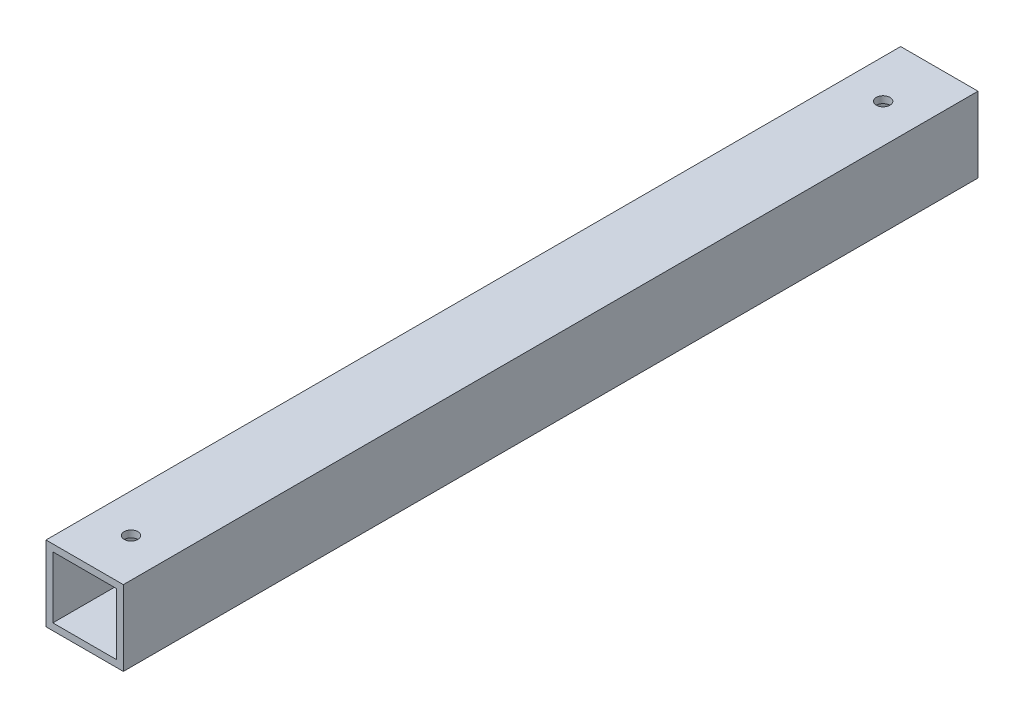
from build123d import *

# Parameters (mm, degrees)
SKETCH1_W           = 45.25
SKETCH1_H           = 44
SKETCH1_W_2         = 37.25
SKETCH1_H_2         = 36
EXTRUDE_THIN1_DEPTH = 250
SKETCH2_R           = 4
CUT_EXTRUDE1_DEPTH  = 45


with BuildPart() as part:
    # Sketch1 → Extrude-Thin1 (new body, symmetric)
    with BuildSketch(Plane.XY):
        Rectangle(SKETCH1_W, SKETCH1_H)
        Rectangle(SKETCH1_W_2, SKETCH1_H_2, mode=Mode.SUBTRACT)
    extrude(amount=EXTRUDE_THIN1_DEPTH, both=True)

    # Sketch2 → Cut-Extrude1 (cut, through all)
    with BuildSketch(Plane(origin=(0, 22, 0), x_dir=(1, 0, 0), z_dir=(0, 1, 0))):
        with Locations((0, 217.131701203)):
            Circle(SKETCH2_R)
        with Locations((0, -222.868298797)):
            Circle(SKETCH2_R)
    extrude(amount=-CUT_EXTRUDE1_DEPTH, mode=Mode.SUBTRACT)


solid = part.part
